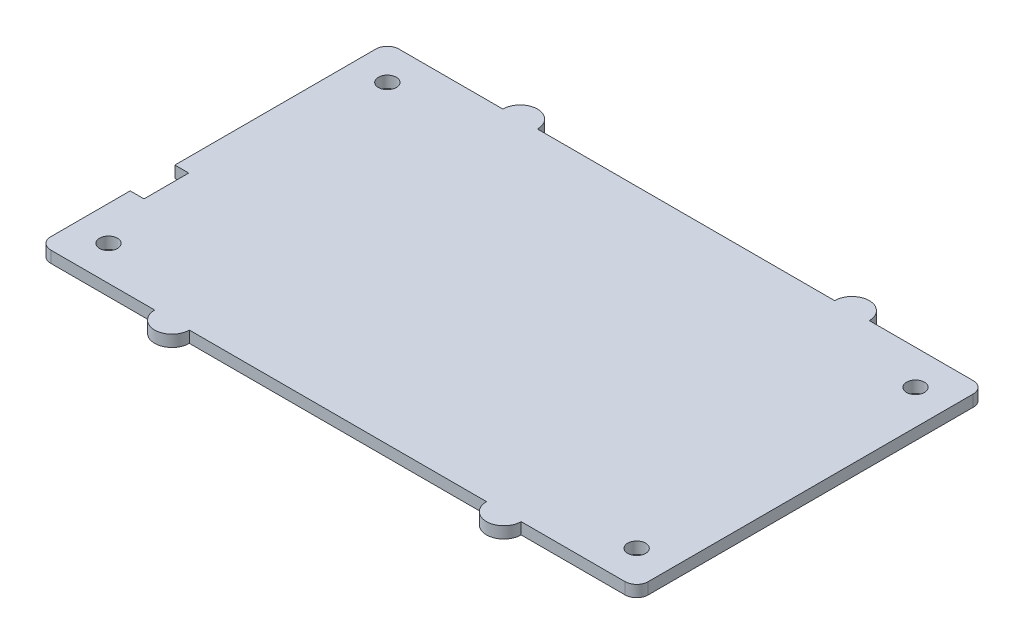
from build123d import *

# Parameters (mm, degrees)
SKETCH_1_R      = 1.55
EXTRUDE_1_DEPTH = 2


with BuildPart() as part:
    # 草图1 → 凸台-拉伸1 (new body)
    with BuildSketch(Plane(origin=(0, 0, 0), x_dir=(1, 0, 0), z_dir=(0, 1, 0))):
        with BuildLine():
            Line((97.46, -4), (97.46, 52.29))
            ThreePointArc((97.46, 52.29), (96.874213562, 53.704213562), (95.46, 54.29))
            Line((95.46, 54.29), (77.46, 54.29))
            ThreePointArc((77.46, 54.29), (74.46, 57.29), (71.46, 54.29))
            Line((71.46, 54.29), (20, 54.29))
            ThreePointArc((20, 54.29), (17, 57.29), (14, 54.29))
            Line((14, 54.29), (-4, 54.29))
            ThreePointArc((-4, 54.29), (-5.414213562, 53.704213562), (-6, 52.29))
            Line((-6, 52.29), (-6, 17.493898271))
            Line((-6, 17.493898271), (-3.6, 17.493898271))
            Line((-3.6, 17.493898271), (-3.6, 9.75))
            Line((-3.6, 9.75), (-6, 9.75))
            Line((-6, 9.75), (-6, -4))
            ThreePointArc((-6, -4), (-5.414213562, -5.414213562), (-4, -6))
            Line((-4, -6), (14, -6))
            ThreePointArc((14, -6), (17, -9), (20, -6))
            Line((20, -6), (71.46, -6))
            ThreePointArc((71.46, -6), (74.46, -9), (77.46, -6))
            Line((77.46, -6), (95.46, -6))
            ThreePointArc((95.46, -6), (96.874213562, -5.414213562), (97.46, -4))
        make_face()
        Circle(SKETCH_1_R, mode=Mode.SUBTRACT)
        with Locations((91.46, 0)):
            Circle(SKETCH_1_R, mode=Mode.SUBTRACT)
        with Locations((0, 48.29)):
            Circle(SKETCH_1_R, mode=Mode.SUBTRACT)
        with Locations((91.46, 48.29)):
            Circle(SKETCH_1_R, mode=Mode.SUBTRACT)
    extrude(amount=EXTRUDE_1_DEPTH)


solid = part.part
